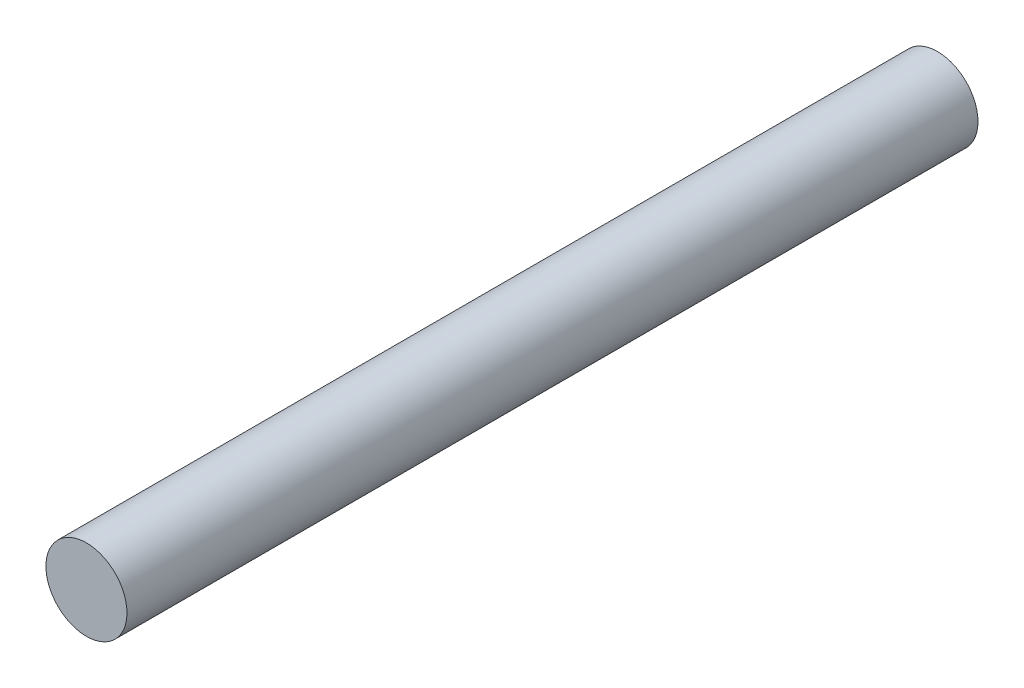
from build123d import *

# Parameters (mm, degrees)
SKETCH1_R           = 12.7
BOSS_EXTRUDE1_DEPTH = 266.7


with BuildPart() as part:
    # Sketch1 → Boss-Extrude1 (new body)
    with BuildSketch(Plane.XY):
        with Locations((0, -1.085701036)):
            Circle(SKETCH1_R)
    extrude(amount=BOSS_EXTRUDE1_DEPTH)


solid = part.part
